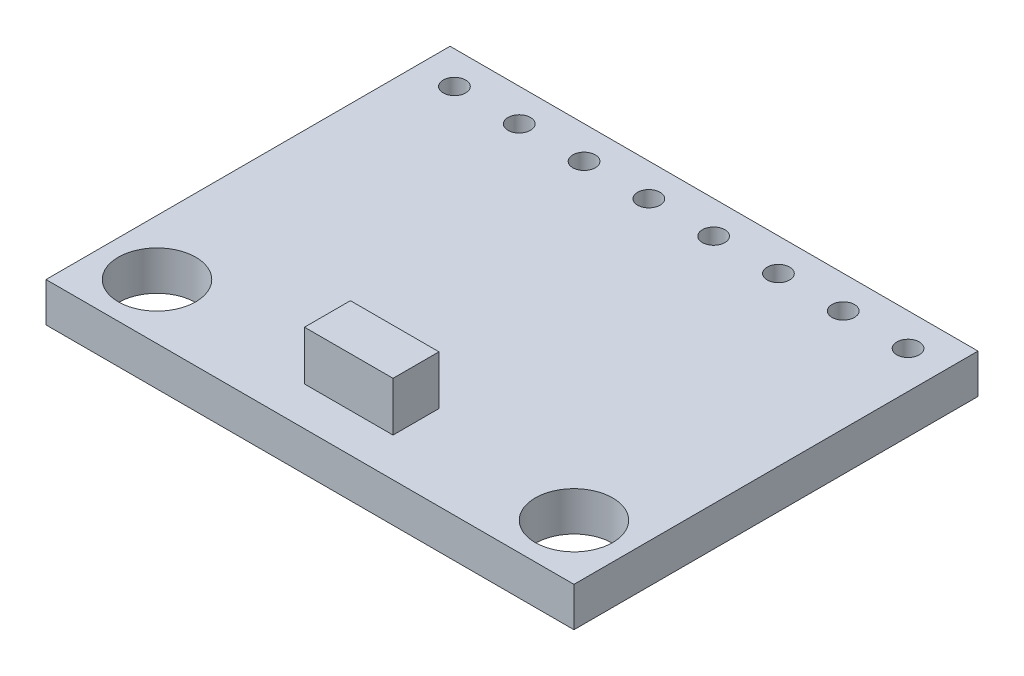
from build123d import *

# Parameters (mm, degrees)
SKETCH1_W           = 20.45
SKETCH1_H           = 15.65
SKETCH1_R           = 1.5
SKETCH1_R_2         = 0.435
BOSS_EXTRUDE1_DEPTH = 1.524
SKETCH2_W           = 3.429
SKETCH2_H           = 1.778
BOSS_EXTRUDE2_DEPTH = 1.905


with BuildPart() as part:
    # Sketch1 → Boss-Extrude1 (new body)
    with BuildSketch(Plane(origin=(0, 0, 0), x_dir=(1, 0, 0), z_dir=(0, 1, 0))):
        with Locations((10.225, 7.825)):
            Rectangle(SKETCH1_W, SKETCH1_H)
        with Locations((2.15, 2.15)):
            Circle(SKETCH1_R, mode=Mode.SUBTRACT)
        with Locations((18.3, 2.15)):
            Circle(SKETCH1_R, mode=Mode.SUBTRACT)
        with Locations((1.435, 14.385)):
            Circle(SKETCH1_R_2, mode=Mode.SUBTRACT)
        with Locations((8.965, 14.385)):
            Circle(SKETCH1_R_2, mode=Mode.SUBTRACT)
        with Locations((6.455, 14.385)):
            Circle(SKETCH1_R_2, mode=Mode.SUBTRACT)
        with Locations((13.985, 14.385)):
            Circle(SKETCH1_R_2, mode=Mode.SUBTRACT)
        with Locations((11.475, 14.385)):
            Circle(SKETCH1_R_2, mode=Mode.SUBTRACT)
        with Locations((3.945, 14.385)):
            Circle(SKETCH1_R_2, mode=Mode.SUBTRACT)
        with Locations((16.495, 14.385)):
            Circle(SKETCH1_R_2, mode=Mode.SUBTRACT)
        with Locations((19.005, 14.385)):
            Circle(SKETCH1_R_2, mode=Mode.SUBTRACT)
    extrude(amount=BOSS_EXTRUDE1_DEPTH)

    # Sketch2 → Boss-Extrude2 (add)
    with BuildSketch(Plane(origin=(0, 1.524, 0), x_dir=(1, 0, 0), z_dir=(0, 1, 0))):
        with Locations((10.225, 2.391364263)):
            Rectangle(SKETCH2_W, SKETCH2_H)
    extrude(amount=BOSS_EXTRUDE2_DEPTH)


solid = part.part
